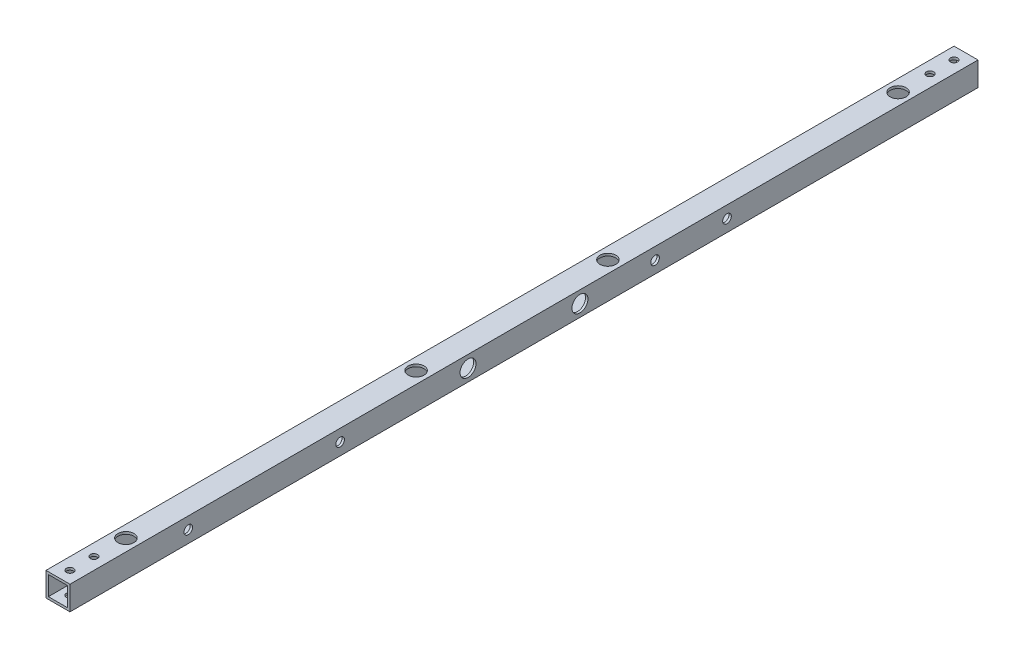
from build123d import *

# Parameters (mm, degrees)
SKETCH_1_W                  = 15
SKETCH_1_H                  = 15
SKETCH_1_W_2                = 12
SKETCH_1_H_2                = 12
EXTRUDE_1_DEPTH             = 568
SKETCH_5_R                  = 2.25
SKETCH_5_R_2                = 2.7
CUT_EXTRUDE_4_DEPTH         = 20
SKETCH_9_R                  = 2.7
CUT_EXTRUDE_6_DEPTH         = 40
SKETCH_10_R                 = 5
CUT_EXTRUDE_7_DEPTH         = 5
SKETCH_13_R                 = 2.25
CUT_EXTRUDE_10_DEPTH        = 40
SKETCH_14_R                 = 5
CUT_EXTRUDE_11_DEPTH        = 5
HOLE_WIZARD_10_0_10_1_D     = 10
HOLE_WIZARD_10_0_10_1_DEPTH = 1.5


with BuildPart() as part:
    # ｽｹｯﾁ1 → ﾎﾞｽ - 押し出し1 (new body)
    with BuildSketch(Plane.XY):
        Rectangle(SKETCH_1_W, SKETCH_1_H)
        Rectangle(SKETCH_1_W_2, SKETCH_1_H_2, mode=Mode.SUBTRACT)
    extrude(amount=EXTRUDE_1_DEPTH)

    # ｽｹｯﾁ5 → ｶｯﾄ - 押し出し4 (cut)
    with BuildSketch(Plane(origin=(0, -7.5, 0), x_dir=(-1, 0, 0), z_dir=(0, -1, 0))):
        with Locations((0, -22.5)):
            Circle(SKETCH_5_R)
        with Locations((0, -7.5)):
            Circle(SKETCH_5_R)
        with Locations((0, -560.5)):
            Circle(SKETCH_5_R)
        with Locations((0, -545.5)):
            Circle(SKETCH_5_R)
        with Locations((0, -42.5)):
            Circle(SKETCH_5_R_2)
        with Locations((0, -224)):
            Circle(SKETCH_5_R_2)
        with Locations((0, -344)):
            Circle(SKETCH_5_R_2)
        with Locations((0, -525.5)):
            Circle(SKETCH_5_R_2)
    extrude(amount=-CUT_EXTRUDE_4_DEPTH, mode=Mode.SUBTRACT)

    # ｽｹｯﾁ9 → ｶｯﾄ - 押し出し6 (cut)
    with BuildSketch(Plane(origin=(7.5, 0, 0), x_dir=(0, 0, -1), z_dir=(1, 0, 0))):
        with Locations((-494, 0)):
            Circle(SKETCH_9_R)
        with Locations((-399, 0)):
            Circle(SKETCH_9_R)
        with Locations((-202, 0)):
            Circle(SKETCH_9_R)
        with Locations((-157, 0)):
            Circle(SKETCH_9_R)
    extrude(amount=-CUT_EXTRUDE_6_DEPTH, mode=Mode.SUBTRACT)

    # ｽｹｯﾁ10 → ｶｯﾄ - 押し出し7 (cut)
    with BuildSketch(Plane.ZY.offset(7.5)):
        with Locations((157, 0)):
            Circle(SKETCH_10_R)
        with Locations((202, 0)):
            Circle(SKETCH_10_R)
        with Locations((399, 0)):
            Circle(SKETCH_10_R)
        with Locations((494, 0)):
            Circle(SKETCH_10_R)
    extrude(amount=-CUT_EXTRUDE_7_DEPTH, mode=Mode.SUBTRACT)

    # ｽｹｯﾁ13 → ｶｯﾄ - 押し出し10 (cut)
    with BuildSketch(Plane(origin=(7.5, 0, 0), x_dir=(0, 0, -1), z_dir=(1, 0, 0))):
        with Locations((-319, 0)):
            Circle(SKETCH_13_R)
        with Locations((-249, 0)):
            Circle(SKETCH_13_R)
    extrude(amount=-CUT_EXTRUDE_10_DEPTH, mode=Mode.SUBTRACT)

    # ｽｹｯﾁ14 → ｶｯﾄ - 押し出し11 (cut)
    with BuildSketch(Plane(origin=(7.5, 0, 0), x_dir=(0, 0, -1), z_dir=(1, 0, 0))):
        with Locations((-319, 0)):
            Circle(SKETCH_14_R)
        with Locations((-249, 0)):
            Circle(SKETCH_14_R)
    extrude(amount=-CUT_EXTRUDE_11_DEPTH, mode=Mode.SUBTRACT)

    # Ø10.0 (10) 直径の穴1
    with Locations(Plane(origin=(0, 7.5, 0), x_dir=(1, 0, 0), z_dir=(0, 1, 0))):
        with Locations((0, -42.5), (0, -224), (0, -344), (0, -525.5)):
            Hole(HOLE_WIZARD_10_0_10_1_D / 2, depth=HOLE_WIZARD_10_0_10_1_DEPTH)


solid = part.part
